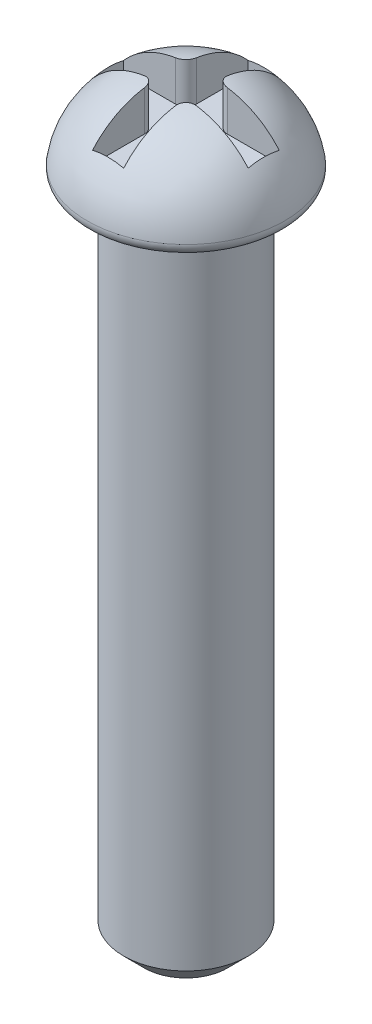
from build123d import *

# Parameters (mm, degrees)
CHAMFER1_SIZE      = 0.5
CUT_EXTRUDE3_DEPTH = 1


with BuildPart() as part:
    # Sketch1 → Revolve1 (revolve)
    with BuildSketch(Plane.XY):
        with BuildLine():
            Line((0, 0), (-1.5, 0))
            Line((-1.5, 0), (-1.5, 15.75))
            ThreePointArc((-1.5, 15.75), (-1.573223305, 15.926776695), (-1.75, 16))
            Line((-1.75, 16), (-2.132389685, 16))
            ThreePointArc((-2.132389685, 16), (-2.321151019, 16.086081853), (-2.379920949, 16.285046729))
            ThreePointArc((-2.379920949, 16.285046729), (-1.555396609, 17.649656197), (0, 18))
            Line((0, 18), (0, 0))
        make_face()
    revolve(axis=Axis((0, 0, 0), (0, 1, 0)))

    # Chamfer1
    chamfer1_edges = [part.edges().sort_by_distance(p)[0] for p in [
        (1.5, 0, 0),
    ]]
    chamfer(chamfer1_edges, length=CHAMFER1_SIZE)

    # Sketch9 → Cut-Extrude3 (cut)
    with BuildSketch(Plane(origin=(0, 18.033333333, 0), x_dir=(1, 0, 0), z_dir=(0, 1, 0))):
        with BuildLine():
            Line((-0.375, 1.875), (0.375, 1.875))
            Line((0.375, 1.875), (0.375, 0.625))
            ThreePointArc((0.375, 0.625), (0.448223305, 0.448223305), (0.625, 0.375))
            Line((0.625, 0.375), (1.875, 0.375))
            Line((1.875, 0.375), (1.875, -0.375))
            Line((1.875, -0.375), (0.625, -0.375))
            ThreePointArc((0.625, -0.375), (0.448223305, -0.448223305), (0.375, -0.625))
            Line((0.375, -0.625), (0.375, -1.875))
            Line((0.375, -1.875), (-0.375, -1.875))
            Line((-0.375, -1.875), (-0.375, -0.625))
            ThreePointArc((-0.375, -0.625), (-0.448223305, -0.448223305), (-0.625, -0.375))
            Line((-0.625, -0.375), (-1.875, -0.375))
            Line((-1.875, -0.375), (-1.875, 0.375))
            Line((-1.875, 0.375), (-0.625, 0.375))
            ThreePointArc((-0.625, 0.375), (-0.448223305, 0.448223305), (-0.375, 0.625))
            Line((-0.375, 0.625), (-0.375, 1.875))
        make_face()
    extrude(amount=-CUT_EXTRUDE3_DEPTH, mode=Mode.SUBTRACT)


solid = part.part
